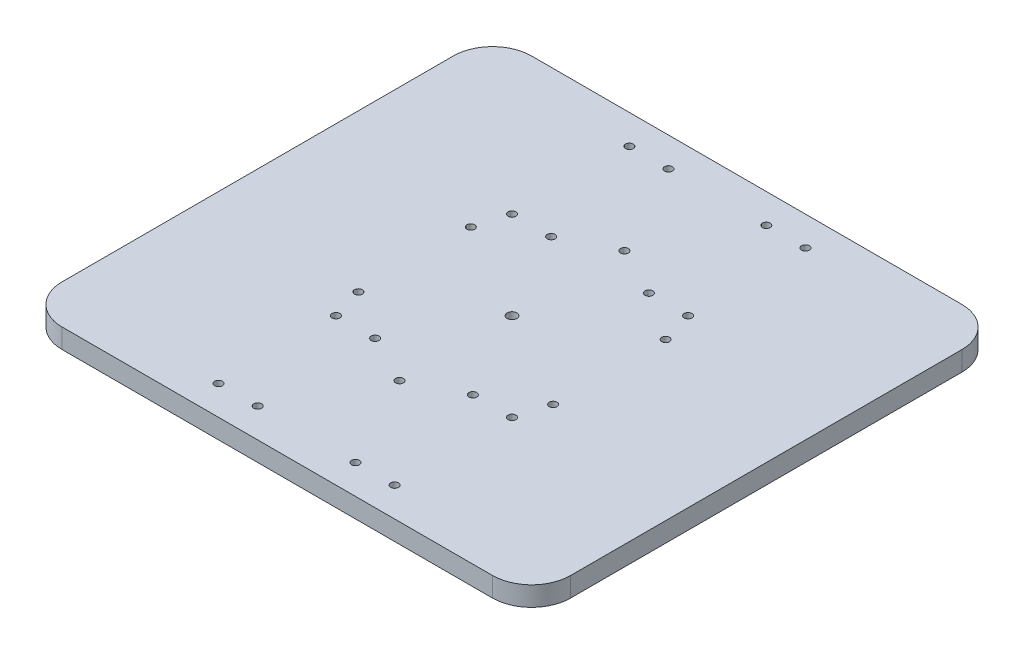
from build123d import *

# Parameters (mm, degrees)
SKETCH1_W           = 260
SKETCH1_H           = 240
BOSS_EXTRUDE1_DEPTH = 10
FILLET3_R           = 20
SKETCH3_R           = 2.5
SKETCH3_R_2         = 2
CUT_EXTRUDE2_DEPTH  = 10


with BuildPart() as part:
    # Sketch1 → Boss-Extrude1 (new body)
    with BuildSketch(Plane(origin=(0, 0, 0), x_dir=(1, 0, 0), z_dir=(0, 1, 0))):
        Rectangle(SKETCH1_W, SKETCH1_H)
    extrude(amount=BOSS_EXTRUDE1_DEPTH)

    # Fillet3
    fillet3_edges = [part.edges().sort_by_distance(p)[0] for p in [
        (130, 5, 120),
        (-130, 5, 120),
        (-130, 5, -120),
        (130, 5, -120),
    ]]
    fillet(fillet3_edges, radius=FILLET3_R)

    # Sketch3 → Cut-Extrude2 (cut)
    with BuildSketch(Plane(origin=(0, 10, 0), x_dir=(1, 0, 0), z_dir=(0, 1, 0))):
        Circle(SKETCH3_R)
        with Locations((0, 57.5)):
            Circle(SKETCH3_R_2)
        with Locations((45, 45)):
            Circle(SKETCH3_R_2)
        with Locations((-45, 45)):
            Circle(SKETCH3_R_2)
        with Locations((45, 105)):
            Circle(SKETCH3_R_2)
        with Locations((-45, 105)):
            Circle(SKETCH3_R_2)
        with Locations((25, 105)):
            Circle(SKETCH3_R_2)
        with Locations((-25, 105)):
            Circle(SKETCH3_R_2)
        with Locations((0, -57.5)):
            Circle(SKETCH3_R_2)
        with Locations((49.796460718, -28.75)):
            Circle(SKETCH3_R_2)
        with Locations((49.796460718, 28.75)):
            Circle(SKETCH3_R_2)
        with Locations((45, -105)):
            Circle(SKETCH3_R_2)
        with Locations((45, -45)):
            Circle(SKETCH3_R_2)
        with Locations((25, -45)):
            Circle(SKETCH3_R_2)
        with Locations((-25, -45)):
            Circle(SKETCH3_R_2)
        with Locations((-45, -45)):
            Circle(SKETCH3_R_2)
        with Locations((25, 45)):
            Circle(SKETCH3_R_2)
        with Locations((-25, 45)):
            Circle(SKETCH3_R_2)
        with Locations((-49.796460718, -28.75)):
            Circle(SKETCH3_R_2)
        with Locations((-45, -105)):
            Circle(SKETCH3_R_2)
        with Locations((-25, -105)):
            Circle(SKETCH3_R_2)
        with Locations((25, -105)):
            Circle(SKETCH3_R_2)
        with Locations((-49.796460718, 28.75)):
            Circle(SKETCH3_R_2)
    extrude(amount=-CUT_EXTRUDE2_DEPTH, mode=Mode.SUBTRACT)


solid = part.part
